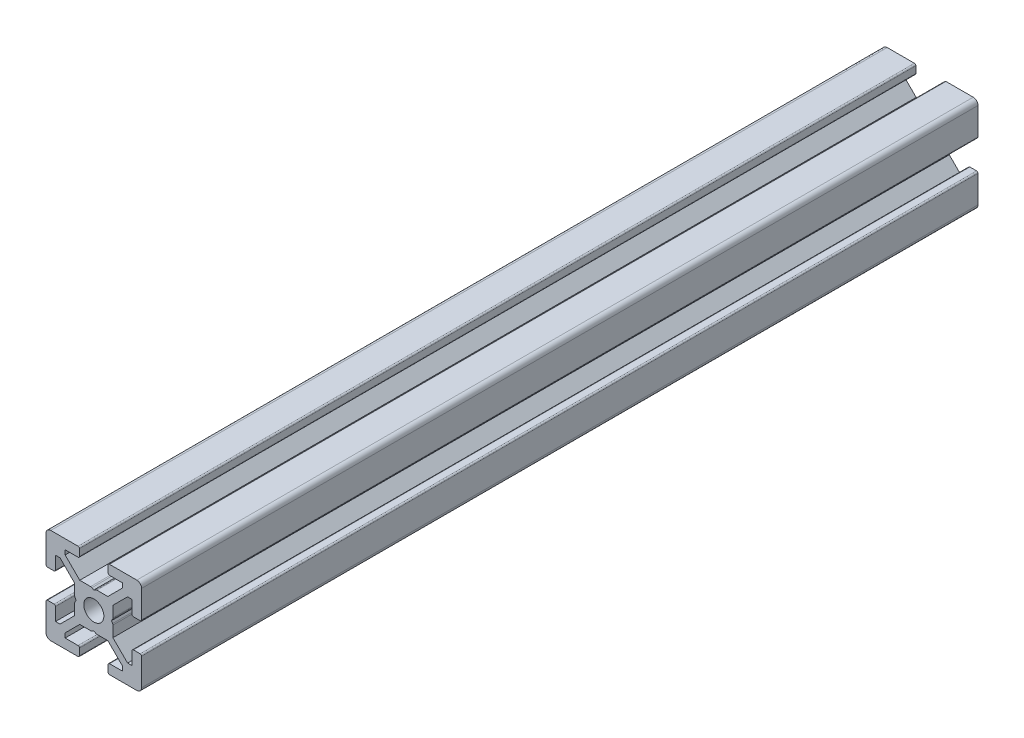
from build123d import *

# Parameters (mm, degrees)
BOSS_EXTRUDE1_DEPTH = 175


with BuildPart() as part:
    # Model → Boss-Extrude1 (new body)
    with BuildSketch(Plane.XY):
        with BuildLine():
            Line((-3, 8.3), (-3, 9.7))
            ThreePointArc((-3, 9.7), (-3.087867966, 9.912132034), (-3.3, 10))
            Line((-3.3, 10), (-9, 10))
            ThreePointArc((-9, 10), (-9.707106781, 9.707106781), (-10, 9))
            Line((-10, 9), (-10, 3.3))
            ThreePointArc((-10, 3.3), (-9.912132034, 3.087867966), (-9.7, 3))
            Line((-9.7, 3), (-8.3, 3))
            ThreePointArc((-8.3, 3), (-8.087867966, 3.087867966), (-8, 3.3))
            Line((-8, 3.3), (-8, 6))
            Line((-8, 6), (-7.060660172, 6))
            Line((-7.060660172, 6), (-4, 2.939339828))
            Line((-4, 2.939339828), (-4, 0.653589838))
            ThreePointArc((-4, 0.653589838), (-3.982962913, 0.524180316), (-3.933012702, 0.403589838))
            Line((-3.933012702, 0.403589838), (-3.7, 0))
            Line((-3.7, 0), (-3.933012702, -0.403589838))
            ThreePointArc((-3.933012702, -0.403589838), (-3.982962913, -0.524180316), (-4, -0.653589838))
            Line((-4, -0.653589838), (-4, -2.939339828))
            Line((-4, -2.939339828), (-7.060660172, -6))
            Line((-7.060660172, -6), (-8, -6))
            Line((-8, -6), (-8, -3.3))
            ThreePointArc((-8, -3.3), (-8.087867966, -3.087867966), (-8.3, -3))
            Line((-8.3, -3), (-9.7, -3))
            ThreePointArc((-9.7, -3), (-9.912132034, -3.087867966), (-10, -3.3))
            Line((-10, -3.3), (-10, -9))
            ThreePointArc((-10, -9), (-9.707106781, -9.707106781), (-9, -10))
            Line((-9, -10), (-3.3, -10))
            ThreePointArc((-3.3, -10), (-3.087867966, -9.912132034), (-3, -9.7))
            Line((-3, -9.7), (-3, -8.3))
            ThreePointArc((-3, -8.3), (-3.087867966, -8.087867966), (-3.3, -8))
            Line((-3.3, -8), (-6, -8))
            Line((-6, -8), (-6, -7.060660172))
            Line((-6, -7.060660172), (-2.939339828, -4))
            Line((-2.939339828, -4), (-0.653589838, -4))
            ThreePointArc((-0.653589838, -4), (-0.524180316, -3.982962913), (-0.403589838, -3.933012702))
            Line((-0.403589838, -3.933012702), (0, -3.7))
            Line((0, -3.7), (0.403589838, -3.933012702))
            ThreePointArc((0.403589838, -3.933012702), (0.524180316, -3.982962913), (0.653589838, -4))
            Line((0.653589838, -4), (2.939339828, -4))
            Line((2.939339828, -4), (6, -7.060660172))
            Line((6, -7.060660172), (6, -8))
            Line((6, -8), (3.3, -8))
            ThreePointArc((3.3, -8), (3.087867966, -8.087867966), (3, -8.3))
            Line((3, -8.3), (3, -9.7))
            ThreePointArc((3, -9.7), (3.087867966, -9.912132034), (3.3, -10))
            Line((3.3, -10), (9, -10))
            ThreePointArc((9, -10), (9.707106781, -9.707106781), (10, -9))
            Line((10, -9), (10, -3.3))
            ThreePointArc((10, -3.3), (9.912132034, -3.087867966), (9.7, -3))
            Line((9.7, -3), (8.3, -3))
            ThreePointArc((8.3, -3), (8.087867966, -3.087867966), (8, -3.3))
            Line((8, -3.3), (8, -6))
            Line((8, -6), (7.060660172, -6))
            Line((7.060660172, -6), (4, -2.939339828))
            Line((4, -2.939339828), (4, -0.653589838))
            ThreePointArc((4, -0.653589838), (3.982962913, -0.524180316), (3.933012702, -0.403589838))
            Line((3.933012702, -0.403589838), (3.7, 0))
            Line((3.7, 0), (3.933012702, 0.403589838))
            ThreePointArc((3.933012702, 0.403589838), (3.982962913, 0.524180316), (4, 0.653589838))
            Line((4, 0.653589838), (4, 2.939339828))
            Line((4, 2.939339828), (7.060660172, 6))
            Line((7.060660172, 6), (8, 6))
            Line((8, 6), (8, 3.3))
            ThreePointArc((8, 3.3), (8.087867966, 3.087867966), (8.3, 3))
            Line((8.3, 3), (9.7, 3))
            ThreePointArc((9.7, 3), (9.912132034, 3.087867966), (10, 3.3))
            Line((10, 3.3), (10, 9))
            ThreePointArc((10, 9), (9.707106781, 9.707106781), (9, 10))
            Line((9, 10), (3.3, 10))
            ThreePointArc((3.3, 10), (3.087867966, 9.912132034), (3, 9.7))
            Line((3, 9.7), (3, 8.3))
            ThreePointArc((3, 8.3), (3.087867966, 8.087867966), (3.3, 8))
            Line((3.3, 8), (6, 8))
            Line((6, 8), (6, 7.060660172))
            Line((6, 7.060660172), (2.939339828, 4))
            Line((2.939339828, 4), (0.653589838, 4))
            ThreePointArc((0.653589838, 4), (0.524180316, 3.982962913), (0.403589838, 3.933012702))
            Line((0.403589838, 3.933012702), (0, 3.7))
            Line((0, 3.7), (-0.403589838, 3.933012702))
            ThreePointArc((-0.403589838, 3.933012702), (-0.524180316, 3.982962913), (-0.653589838, 4))
            Line((-0.653589838, 4), (-2.939339828, 4))
            Line((-2.939339828, 4), (-6, 7.060660172))
            Line((-6, 7.060660172), (-6, 8))
            Line((-6, 8), (-3.3, 8))
            ThreePointArc((-3.3, 8), (-3.087867966, 8.087867966), (-3, 8.3))
        make_face()
        with BuildLine():
            ThreePointArc((-2.1, 0), (-1.48492424, -1.48492424), (0, -2.1))
            ThreePointArc((0, -2.1), (1.48492424, -1.48492424), (2.1, 0))
            ThreePointArc((2.1, 0), (1.48492424, 1.48492424), (0, 2.1))
            ThreePointArc((0, 2.1), (-1.48492424, 1.48492424), (-2.1, 0))
        make_face(mode=Mode.SUBTRACT)
    extrude(amount=BOSS_EXTRUDE1_DEPTH)


solid = part.part
